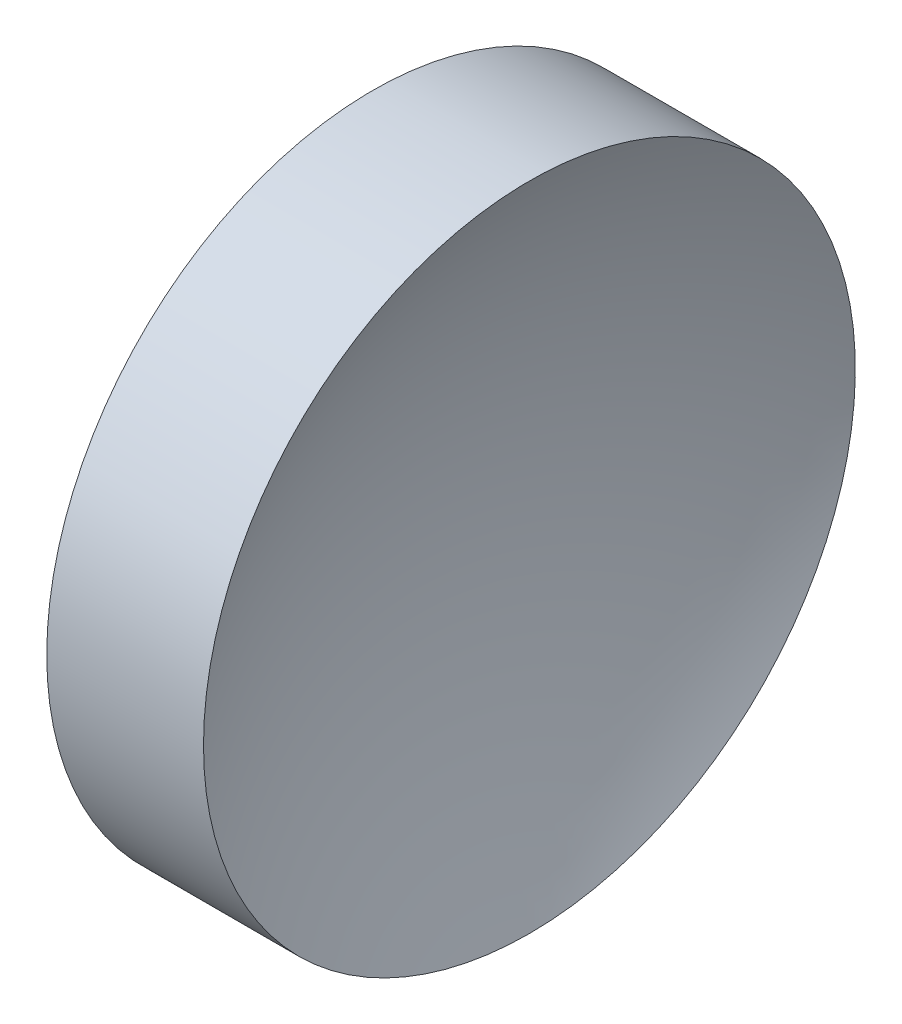
from build123d import *


with BuildPart() as part:
    # 草图1 → 旋转1 (revolve)
    with BuildSketch(Plane.XY, mode=Mode.PRIVATE) as revolve_1_sk:
        with BuildLine():
            Line((47.753708501, 28.477595635), (47.753708501, 34.827595635))
            Line((47.753708501, 34.827595635), (50.807807551, 34.827595635))
            ThreePointArc((50.807807551, 34.827595635), (49.647883217, 31.746300418), (49.253708501, 28.477595635))
            Line((49.253708501, 28.477595635), (47.753708501, 28.477595635))
        make_face()
    revolve(revolve_1_sk.sketch.rotate(Axis((44.782091903, 28.477595635, 0), (1, 0, 0)), 180), axis=Axis((44.782091903, 28.477595635, 0), (1, 0, 0)))  # turned: the seam where the file's is


solid = part.part
